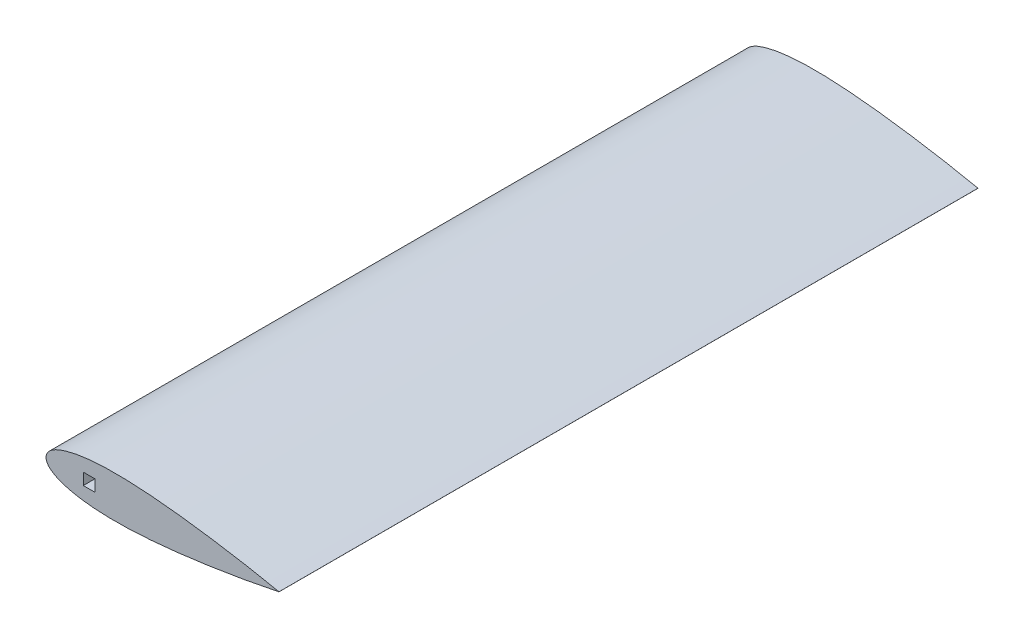
from build123d import *

# Parameters (mm, degrees)
BOSS_EXTRUDE1_DEPTH     = 600
SKETCH6_W               = 10
SKETCH6_H               = 5
CUT_EXTRUDE2_DEPTH      = 656
SKETCH8_W               = 10
SKETCH8_H               = 14
SKETCH8_W_2             = 2
CUT_EXTRUDE4_DEPTH      = 42
CUT_EXTRUDE4_DEPTH_BACK = 2
SKETCH9_W               = 14
SKETCH9_H               = 14
CUT_EXTRUDE5_DEPTH      = 14
SKETCH10_W              = 14
SKETCH10_H              = 14
CUT_EXTRUDE6_DEPTH      = 14
SKETCH11_W              = 10
SKETCH11_H              = 10
CUT_EXTRUDE7_DEPTH      = 654
SKETCH12_W              = 10
SKETCH12_H              = 10
BOSS_EXTRUDE3_DEPTH     = 600
SKETCH13_W              = 10
SKETCH13_H              = 14
CUT_EXTRUDE8_DEPTH      = 10
SKETCH14_W              = 10
SKETCH14_H              = 14
CUT_EXTRUDE9_DEPTH      = 10
SKETCH16_W              = 14
SKETCH16_H              = 4.5
CUT_EXTRUDE10_DEPTH     = 10
SKETCH17_W              = 14
SKETCH17_H              = 4.5
CUT_EXTRUDE11_DEPTH     = 14


with BuildPart() as part:
    # Sketch2 → Boss-Extrude1 (new body)
    with BuildSketch(Plane.XY):
        with BuildLine():
            Line((200, 0.026021305), (200, -0.026021313))
            add(Edge.make_bspline(
                [(200, 0.026021305), (196.133660298, 0.824460007), (188.973100367, 2.314029776), (175.197231938, 4.95350612), (158.682087923, 7.864416996), (138.848303334, 10.963035098), (119.017582397, 13.652387002), (99.186590163, 15.851924276), (79.350823181, 17.41083287), (62.801573061, 17.964567123), (49.570059005, 17.74356646), (39.638389621, 17.155457266), (29.688048318, 16.020003739), (21.406431266, 14.43331701), (14.801094645, 12.546196453), (9.75689383, 10.639636938), (5.531834741, 8.343752603), (1.645401824, 5.168264306), (-1.073716587, 0), (1.645401824, -5.168264306), (5.53183474, -8.343752603), (9.756893829, -10.639636938), (14.801094645, -12.546196453), (21.406431266, -14.43331701), (29.688048318, -16.02000374), (39.63838962, -17.155457267), (49.570059005, -17.743566462), (62.801573061, -17.964567125), (79.350823181, -17.410832873), (99.186590162, -15.85192428), (119.017582396, -13.652387007), (138.848303334, -10.963035103), (158.682087923, -7.864417002), (175.197231937, -4.953506127), (188.973100367, -2.314029784), (196.133660298, -0.824460015), (200, -0.026021313)],
                knots=[-0.004189875, -0.004189875, -0.004189875, -0.004189875, 0.024603844, 0.049152359, 0.098108667, 0.146905312, 0.195554797, 0.244056277, 0.292409554, 0.340643731, 0.364754111, 0.3889056, 0.413178108, 0.437756239, 0.450304697, 0.463229879, 0.477067953, 0.485035559, 0.5, 0.514964441, 0.522932047, 0.536770121, 0.549695303, 0.562243761, 0.586821892, 0.6110944, 0.635245889, 0.659356269, 0.707590446, 0.755943723, 0.804445203, 0.853094688, 0.901891333, 0.950847641, 0.975396156, 1.004189875, 1.004189875, 1.004189875, 1.004189875], degree=3))
        make_face()
    extrude(amount=BOSS_EXTRUDE1_DEPTH)

    # Sketch6 → Cut-Extrude2 (cut)
    with BuildSketch(Plane.XY.offset(600)):
        with Locations((25, 2.5)):
            Rectangle(SKETCH6_W, SKETCH6_H)
        with Locations((25, -2.5)):
            Rectangle(SKETCH6_W, SKETCH6_H)
    extrude(amount=-CUT_EXTRUDE2_DEPTH, mode=Mode.SUBTRACT)

    # Sketch8 → Cut-Extrude4 (cut, two sides)
    with BuildSketch(Plane(origin=(0, 5, 0), x_dir=(-1, 0, 0), z_dir=(0, -1, 0))) as cut_extrude4_sk:
        with Locations((-25, -243)):
            Rectangle(SKETCH8_W, SKETCH8_H)
        with Locations((-25, -357)):
            Rectangle(SKETCH8_W, SKETCH8_H)
        with Locations((-19, -357)):
            Rectangle(SKETCH8_W_2, SKETCH8_H)
        with Locations((-31, -357)):
            Rectangle(SKETCH8_W_2, SKETCH8_H)
        with Locations((-19, -243)):
            Rectangle(SKETCH8_W_2, SKETCH8_H)
        with Locations((-31, -243)):
            Rectangle(SKETCH8_W_2, SKETCH8_H)
    extrude(amount=CUT_EXTRUDE4_DEPTH, mode=Mode.SUBTRACT)
    extrude(cut_extrude4_sk.sketch, amount=-CUT_EXTRUDE4_DEPTH_BACK, mode=Mode.SUBTRACT)

    # Sketch9 → Cut-Extrude5 (cut)
    with BuildSketch(Plane.ZY.offset(-32)):
        with Locations((357, 0)):
            Rectangle(SKETCH9_W, SKETCH9_H)
    extrude(amount=-CUT_EXTRUDE5_DEPTH, mode=Mode.SUBTRACT)

    # Sketch10 → Cut-Extrude6 (cut)
    with BuildSketch(Plane.ZY.offset(-32)):
        with Locations((243, 0)):
            Rectangle(SKETCH10_W, SKETCH10_H)
    extrude(amount=-CUT_EXTRUDE6_DEPTH, mode=Mode.SUBTRACT)

    # Sketch11 → Cut-Extrude7 (cut)
    with BuildSketch(Plane.XY.offset(600)):
        with Locations((37, 0)):
            Rectangle(SKETCH11_W, SKETCH11_H)
    extrude(amount=-CUT_EXTRUDE7_DEPTH, mode=Mode.SUBTRACT)

    # Sketch12 → Boss-Extrude3 (add)
    with BuildSketch(Plane.XY.offset(600)):
        with Locations((25, 0)):
            Rectangle(SKETCH12_W, SKETCH12_H)
    extrude(amount=-BOSS_EXTRUDE3_DEPTH)

    # Sketch13 → Cut-Extrude8 (cut)
    with BuildSketch(Plane(origin=(0, -5, 0), x_dir=(-1, 0, 0), z_dir=(0, -1, 0))):
        with Locations((-25, -243)):
            Rectangle(SKETCH13_W, SKETCH13_H)
    extrude(amount=-CUT_EXTRUDE8_DEPTH, mode=Mode.SUBTRACT)

    # Sketch14 → Cut-Extrude9 (cut)
    with BuildSketch(Plane(origin=(0, -5, 0), x_dir=(-1, 0, 0), z_dir=(0, -1, 0))):
        with Locations((-25, -357)):
            Rectangle(SKETCH14_W, SKETCH14_H)
    extrude(amount=-CUT_EXTRUDE9_DEPTH, mode=Mode.SUBTRACT)

    # Sketch16 → Cut-Extrude10 (cut)
    with BuildSketch(Plane.ZY.offset(-46)):
        with Locations((357, -4.75)):
            Rectangle(SKETCH16_W, SKETCH16_H)
    extrude(amount=-CUT_EXTRUDE10_DEPTH, mode=Mode.SUBTRACT)

    # Sketch17 → Cut-Extrude11 (cut)
    with BuildSketch(Plane.ZY.offset(-46)):
        with Locations((357, -0.25)):
            Rectangle(SKETCH17_W, SKETCH17_H)
    extrude(amount=-CUT_EXTRUDE11_DEPTH, mode=Mode.SUBTRACT)


solid = part.part
